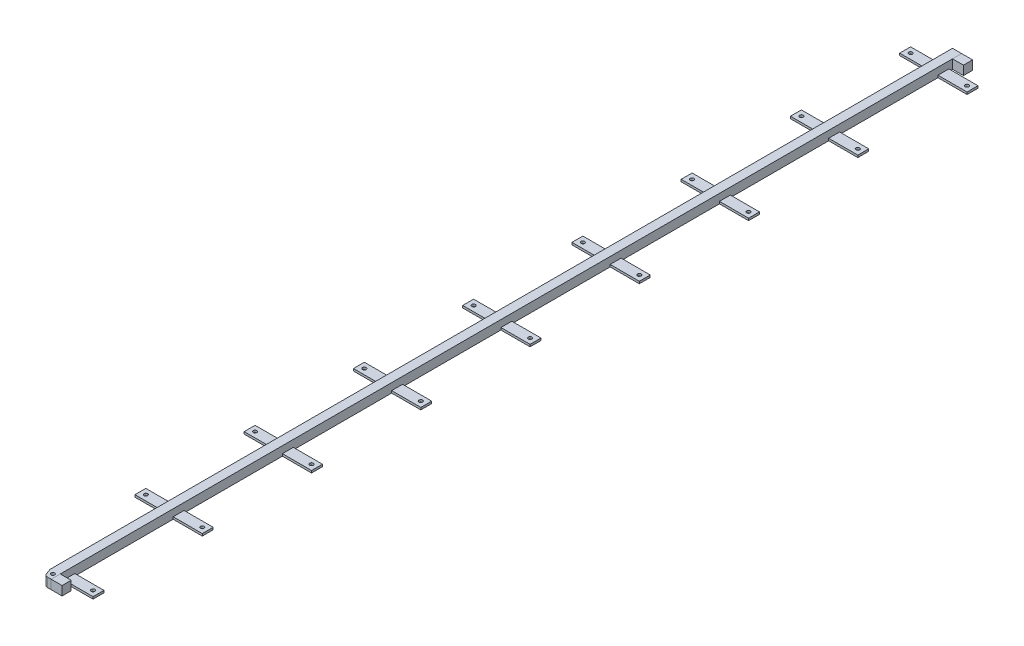
from build123d import *

# Parameters (mm, degrees)
SKETCH_1_W             = 25
SKETCH_1_H             = 2500
EXTRUDE_1_DEPTH        = 25
SKETCH_2_W             = 30
SKETCH_2_H             = 25
EXTRUDE_2_DEPTH        = 25
CHAMFER_1_SIZE         = 22
CHAMFER_1_SIZE2        = 8
FILLET_2_R             = 10
SKETCH_3_W             = 30
SKETCH_3_H             = 25
EXTRUDE_3_DEPTH        = 25
SKETCH_4_W             = 80
SKETCH_4_H             = 30
SKETCH_4_R             = 5
EXTRUDE_4_DEPTH        = 6
EXTRUDE_4_2_DEPTH      = 6
PATTERN_LINEAR_1_COUNT = 9
PATTERN_LINEAR_1_PITCH = 300
SKETCH_5_R             = 5
CUT_EXTRUDE_1_DEPTH    = 25
SKETCH_6_W             = 80
SKETCH_6_H             = 30
CUT_EXTRUDE_2_DEPTH    = 10


with BuildPart() as part:
    # 草图1 → 凸台-拉伸1 (new body)
    with BuildSketch(Plane(origin=(0, 0, 0), x_dir=(1, 0, 0), z_dir=(0, 1, 0))):
        with Locations((12.5, 1250)):
            Rectangle(SKETCH_1_W, SKETCH_1_H)
    extrude(amount=EXTRUDE_1_DEPTH)

    # 倒角1
    chamfer_1_edges = [part.edges().sort_by_distance(p)[0] for p in [
        (0, 12.5, 0),
    ]]
    chamfer_1_side = [part.faces().sort_by_distance(p)[0] for p in [
        (0, 12.5, -1250),
    ]]
    chamfer(chamfer_1_edges, length=CHAMFER_1_SIZE, length2=CHAMFER_1_SIZE2, reference=chamfer_1_side[0])

    # 圆角2
    fillet_2_edges = [part.edges().sort_by_distance(p)[0] for p in [
        (8, 12.5, 0),
        (0, 12.5, -22),
    ]]
    fillet(fillet_2_edges, radius=FILLET_2_R)

    # 草图5 → 切除-拉伸1 (cut)
    with BuildSketch(Plane(origin=(0, 25, 0), x_dir=(1, 0, 0), z_dir=(0, 1, 0))):
        with Locations((15, 15)):
            Circle(SKETCH_5_R)
    extrude(amount=-CUT_EXTRUDE_1_DEPTH, mode=Mode.SUBTRACT)


with BuildPart() as body_2:
    # 草图2 → 凸台-拉伸2 (new body)
    with BuildSketch(Plane(origin=(0, 0, 0), x_dir=(1, 0, 0), z_dir=(0, 1, 0))):
        with Locations((40, 12.5)):
            Rectangle(SKETCH_2_W, SKETCH_2_H)
    extrude(amount=EXTRUDE_2_DEPTH)


with BuildPart() as body_3:
    # 草图3 → 凸台-拉伸3 (new body)
    with BuildSketch(Plane(origin=(0, 0, -2500), x_dir=(-1, 0, 0), z_dir=(0, 0, -1))):
        with Locations((-40, 12.5)):
            Rectangle(SKETCH_3_W, SKETCH_3_H)
    extrude(amount=-EXTRUDE_3_DEPTH)


with BuildPart() as body_4:
    # 草图4 → 凸台-拉伸4 (new body)
    with BuildSketch(Plane(origin=(0, 0, 0), x_dir=(1, 0, 0), z_dir=(0, 1, 0))):
        with Locations((-40, 2450)):
            Rectangle(SKETCH_4_W, SKETCH_4_H)
        with Locations((-65, 2450)):
            Circle(SKETCH_4_R, mode=Mode.SUBTRACT)
    extrude_4 = extrude(amount=EXTRUDE_4_DEPTH)


with BuildPart() as body_5:
    # 草图4 → Extrude 4 2 (new body)
    with BuildSketch(Plane(origin=(0, 0, 0), x_dir=(1, 0, 0), z_dir=(0, 1, 0))):
        with Locations((65, 2450)):
            Rectangle(SKETCH_4_W, SKETCH_4_H)
        with Locations((90, 2450)):
            Circle(SKETCH_4_R, mode=Mode.SUBTRACT)
    extrude_4_2 = extrude(amount=EXTRUDE_4_2_DEPTH)


with BuildPart() as pattern_linear_1_1:
    # 阵列(线性)1: pattern copy
    add(extrude_4.moved(Location(Vector(0, 0, 1) * (1 * PATTERN_LINEAR_1_PITCH))))


with BuildPart() as pattern_linear_1_2:
    # 阵列(线性)1: pattern copy
    add(extrude_4.moved(Location(Vector(0, 0, 1) * (2 * PATTERN_LINEAR_1_PITCH))))


with BuildPart() as pattern_linear_1_3:
    # 阵列(线性)1: pattern copy
    add(extrude_4.moved(Location(Vector(0, 0, 1) * (3 * PATTERN_LINEAR_1_PITCH))))


with BuildPart() as pattern_linear_1_4:
    # 阵列(线性)1: pattern copy
    add(extrude_4.moved(Location(Vector(0, 0, 1) * (4 * PATTERN_LINEAR_1_PITCH))))


with BuildPart() as pattern_linear_1_5:
    # 阵列(线性)1: pattern copy
    add(extrude_4.moved(Location(Vector(0, 0, 1) * (5 * PATTERN_LINEAR_1_PITCH))))


with BuildPart() as pattern_linear_1_6:
    # 阵列(线性)1: pattern copy
    add(extrude_4.moved(Location(Vector(0, 0, 1) * (6 * PATTERN_LINEAR_1_PITCH))))


with BuildPart() as pattern_linear_1_7:
    # 阵列(线性)1: pattern copy
    add(extrude_4.moved(Location(Vector(0, 0, 1) * (7 * PATTERN_LINEAR_1_PITCH))))


with BuildPart() as pattern_linear_1_8:
    # 阵列(线性)1: pattern copy
    add(extrude_4.moved(Location(Vector(0, 0, 1) * (8 * PATTERN_LINEAR_1_PITCH))))

    # 草图6 → 切除-拉伸2 (cut)
    with BuildSketch(Plane(origin=(0, 6, 0), x_dir=(1, 0, 0), z_dir=(0, 1, 0))):
        with Locations((-40, 50)):
            Rectangle(SKETCH_6_W, SKETCH_6_H)
    extrude(amount=-CUT_EXTRUDE_2_DEPTH, mode=Mode.SUBTRACT)


with BuildPart() as pattern_linear_1_9:
    # 阵列(线性)1: pattern copy
    add(extrude_4_2.moved(Location(Vector(0, 0, 1) * (1 * PATTERN_LINEAR_1_PITCH))))


with BuildPart() as pattern_linear_1_10:
    # 阵列(线性)1: pattern copy
    add(extrude_4_2.moved(Location(Vector(0, 0, 1) * (2 * PATTERN_LINEAR_1_PITCH))))


with BuildPart() as pattern_linear_1_11:
    # 阵列(线性)1: pattern copy
    add(extrude_4_2.moved(Location(Vector(0, 0, 1) * (3 * PATTERN_LINEAR_1_PITCH))))


with BuildPart() as pattern_linear_1_12:
    # 阵列(线性)1: pattern copy
    add(extrude_4_2.moved(Location(Vector(0, 0, 1) * (4 * PATTERN_LINEAR_1_PITCH))))


with BuildPart() as pattern_linear_1_13:
    # 阵列(线性)1: pattern copy
    add(extrude_4_2.moved(Location(Vector(0, 0, 1) * (5 * PATTERN_LINEAR_1_PITCH))))


with BuildPart() as pattern_linear_1_14:
    # 阵列(线性)1: pattern copy
    add(extrude_4_2.moved(Location(Vector(0, 0, 1) * (6 * PATTERN_LINEAR_1_PITCH))))


with BuildPart() as pattern_linear_1_15:
    # 阵列(线性)1: pattern copy
    add(extrude_4_2.moved(Location(Vector(0, 0, 1) * (7 * PATTERN_LINEAR_1_PITCH))))


with BuildPart() as pattern_linear_1_16:
    # 阵列(线性)1: pattern copy
    add(extrude_4_2.moved(Location(Vector(0, 0, 1) * (8 * PATTERN_LINEAR_1_PITCH))))


solid = Compound([part.part, body_2.part, body_3.part, body_4.part, body_5.part, pattern_linear_1_1.part, pattern_linear_1_2.part, pattern_linear_1_3.part, pattern_linear_1_4.part, pattern_linear_1_5.part, pattern_linear_1_6.part, pattern_linear_1_7.part, pattern_linear_1_9.part, pattern_linear_1_10.part, pattern_linear_1_11.part, pattern_linear_1_12.part, pattern_linear_1_13.part, pattern_linear_1_14.part, pattern_linear_1_15.part, pattern_linear_1_16.part])
